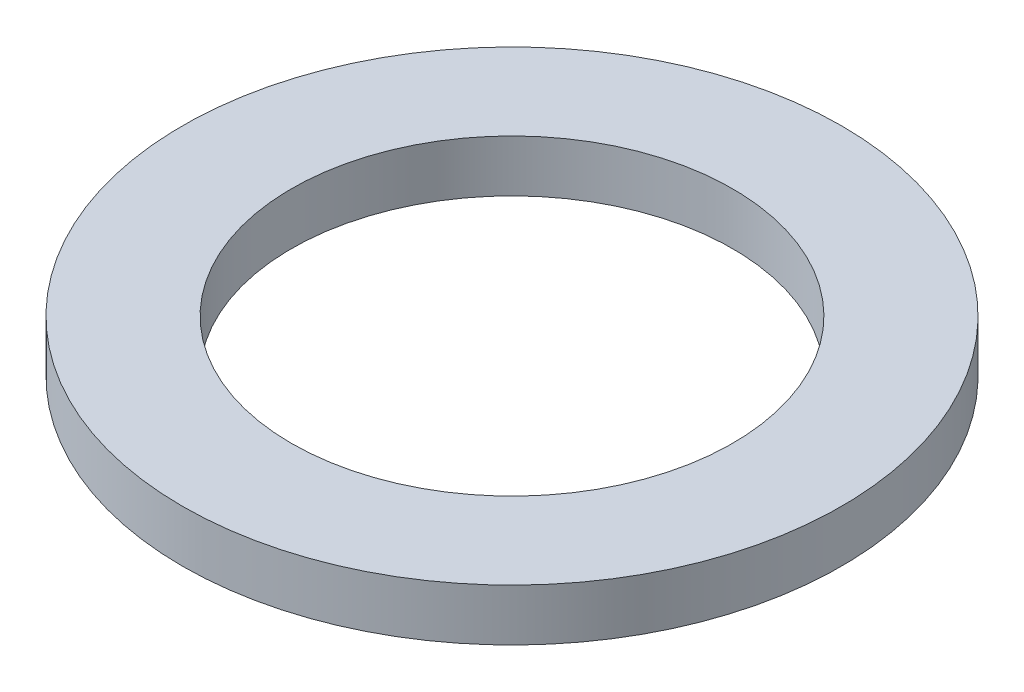
from build123d import *

# Parameters (mm, degrees)
SKETCH1_R           = 12.7
SKETCH1_R_2         = 8.5
BOSS_EXTRUDE1_DEPTH = 2


with BuildPart() as part:
    # Sketch1 → Boss-Extrude1 (new body)
    with BuildSketch(Plane(origin=(0, 0, 0), x_dir=(1, 0, 0), z_dir=(0, 1, 0))):
        Circle(SKETCH1_R)
        Circle(SKETCH1_R_2, mode=Mode.SUBTRACT)
    extrude(amount=BOSS_EXTRUDE1_DEPTH)


solid = part.part
